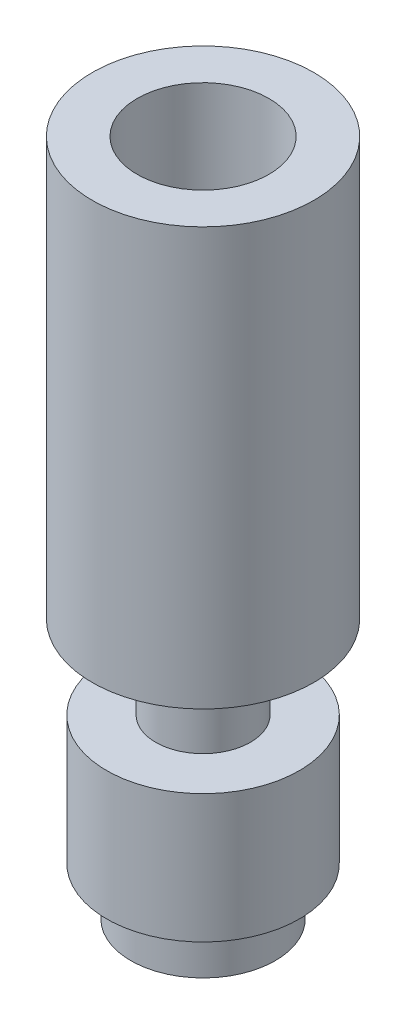
from build123d import *


with BuildPart() as part:
    # Sketch2 → Revolve1 (revolve)
    with BuildSketch(Plane.XY):
        Polygon((-1, 0), (-2.25, 0), (-2.25, 1.5), (-3, 1.5), (-3, 5.5), (-1.475, 5.5), (-1.475, 8.1), (-3.45, 8.1), (-3.45, 21.1), (-2.05, 21.1), (-2.05, 17.1), (-1, 16.541705097), align=None)
    revolve(axis=Axis((0, 0, 0), (0, 1, 0)))


solid = part.part
